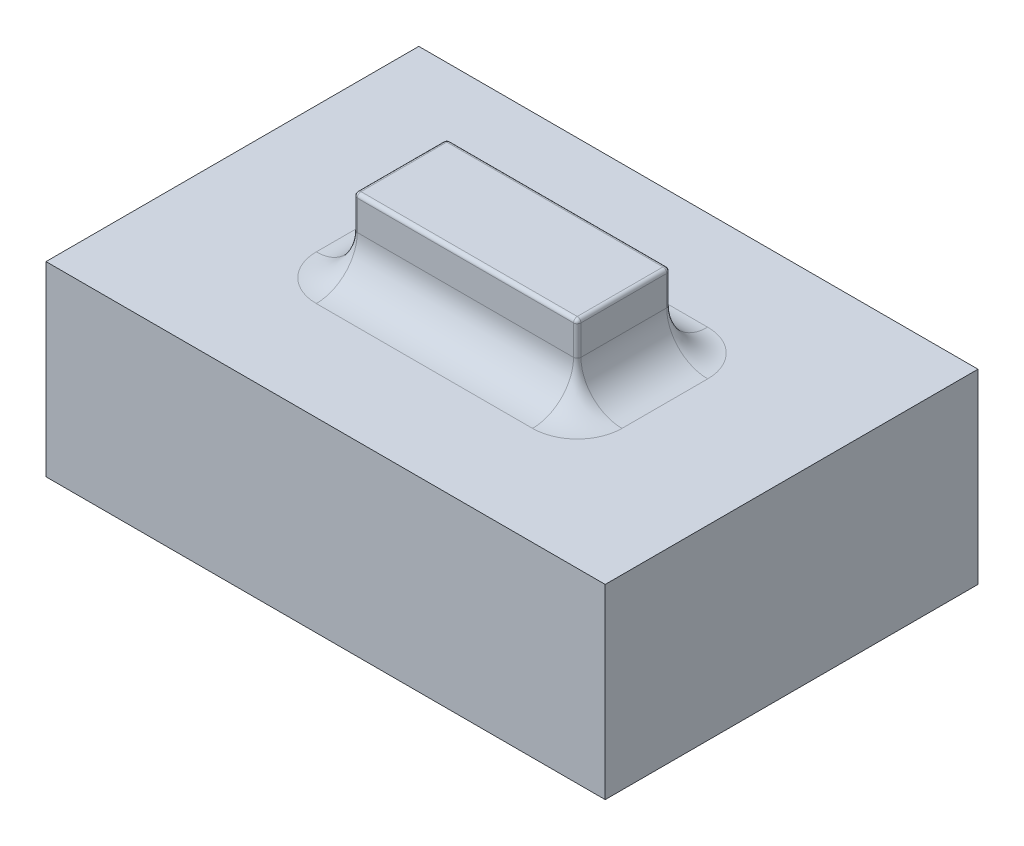
from build123d import *

# Parameters (mm, degrees)
SKETCH_1_W      = 15
SKETCH_1_H      = 10
EXTRUDE_1_DEPTH = 5
SKETCH_2_W      = 6
SKETCH_2_H      = 2.5
EXTRUDE_2_DEPTH = 2
FILLET_1_R      = 0.1
FILLET_2_R      = 1.1
FILLET_3_R      = 0.1


with BuildPart() as part:
    # 草图1 → 凸台-拉伸1 (new body)
    with BuildSketch(Plane(origin=(0, 0, 0), x_dir=(1, 0, 0), z_dir=(0, 1, 0))):
        Rectangle(SKETCH_1_W, SKETCH_1_H)
    extrude(amount=EXTRUDE_1_DEPTH)

    # 草图2 → 凸台-拉伸2 (add)
    with BuildSketch(Plane(origin=(0, 5, 0), x_dir=(1, 0, 0), z_dir=(0, 1, 0))):
        Rectangle(SKETCH_2_W, SKETCH_2_H)
    extrude(amount=EXTRUDE_2_DEPTH)

    # 圆角1
    fillet_1_edges = [part.edges().sort_by_distance(p)[0] for p in [
        (-3, 6, -1.25),
        (-3, 6, 1.25),
        (3, 6, 1.25),
        (3, 6, -1.25),
    ]]
    fillet(fillet_1_edges, radius=FILLET_1_R)

    # 圆角2
    fillet_2_edges = [part.edges().sort_by_distance(p)[0] for p in [
        (-3, 5, 0),
        (0, 5, -1.25),
        (3, 5, 0),
        (0, 5, 1.25),
        (-2.970710678, 5, -1.220710678),
        (2.970710678, 5, -1.220710678),
        (2.970710678, 5, 1.220710678),
        (-2.970710678, 5, 1.220710678),
    ]]
    fillet(fillet_2_edges, radius=FILLET_2_R)

    # 圆角3
    fillet_3_edges = [part.edges().sort_by_distance(p)[0] for p in [
        (-3, 7, 0),
        (0, 7, -1.25),
        (0, 7, 1.25),
        (3, 7, 0),
        (-2.970710678, 7, 1.220710678),
        (2.970710678, 7, 1.220710678),
        (2.970710678, 7, -1.220710678),
        (-2.970710678, 7, -1.220710678),
    ]]
    fillet(fillet_3_edges, radius=FILLET_3_R)


solid = part.part
